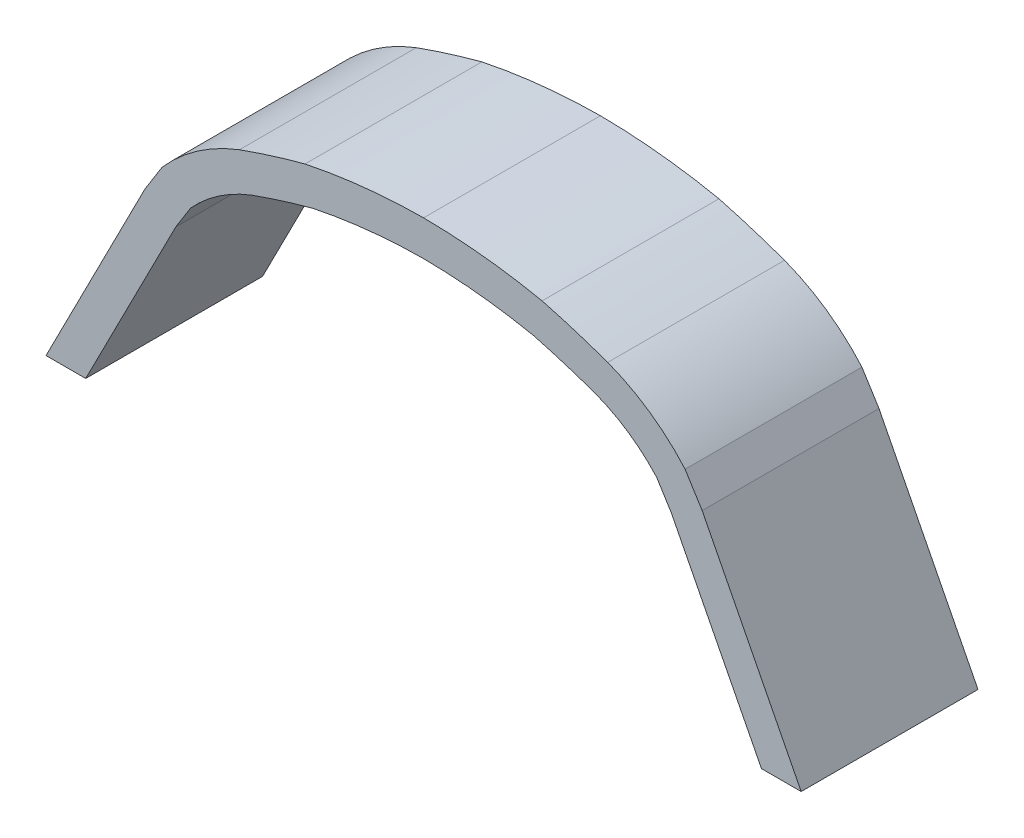
from build123d import *

# Parameters (mm, degrees)
BOSS_EXTRUDE1_DEPTH = 2.54


with BuildPart() as part:
    # Sketch1 → Boss-Extrude1 (new body)
    with BuildSketch(Plane.XY):
        with BuildLine():
            Line((-4.853491174, 0), (-3.559199198, 2.53375457))
            Line((-3.559199198, 2.53375457), (-3.348230277, 2.871336194))
            ThreePointArc((-3.348230277, 2.871336194), (-2.944103246, 3.224381504), (-2.468700609, 3.473283052))
            ThreePointArc((-2.468700609, 3.473283052), (-2.030100497, 3.620676512), (-1.585680864, 3.749463464))
            ThreePointArc((-1.585680864, 3.749463464), (-0.796949472, 3.872230469), (0, 3.917402206))
            ThreePointArc((0, 3.917402206), (0.796949472, 3.872230469), (1.585680864, 3.749463464))
            ThreePointArc((1.585680864, 3.749463464), (2.030100497, 3.620676512), (2.468700609, 3.473283052))
            ThreePointArc((2.468700609, 3.473283052), (2.944103246, 3.224381504), (3.348230277, 2.871336194))
            Line((3.348230277, 2.871336194), (3.559199198, 2.53375457))
            Line((3.559199198, 2.53375457), (4.853491174, 0))
            Line((4.853491174, 0), (5.423931714, 0))
            Line((5.423931714, 0), (4.00161657, 2.78437753))
            Line((4.00161657, 2.78437753), (3.756428721, 3.176714524))
            ThreePointArc((3.756428721, 3.176714524), (3.248333968, 3.631652605), (2.64503979, 3.949717174))
            ThreePointArc((2.64503979, 3.949717174), (2.177010777, 4.106994166), (1.702656867, 4.244018167))
            ThreePointArc((1.702656867, 4.244018167), (0.855815628, 4.376835426), (0, 4.425416473))
            ThreePointArc((0, 4.425416473), (-0.855815628, 4.376835426), (-1.702656867, 4.244018167))
            ThreePointArc((-1.702656867, 4.244018167), (-2.177010777, 4.106994166), (-2.64503979, 3.949717174))
            ThreePointArc((-2.64503979, 3.949717174), (-3.248333968, 3.631652605), (-3.756428721, 3.176714524))
            Line((-3.756428721, 3.176714524), (-4.00161657, 2.78437753))
            Line((-4.00161657, 2.78437753), (-5.423931714, 0))
            Line((-5.423931714, 0), (-4.853491174, 0))
        make_face()
    extrude(amount=BOSS_EXTRUDE1_DEPTH)


solid = part.part
